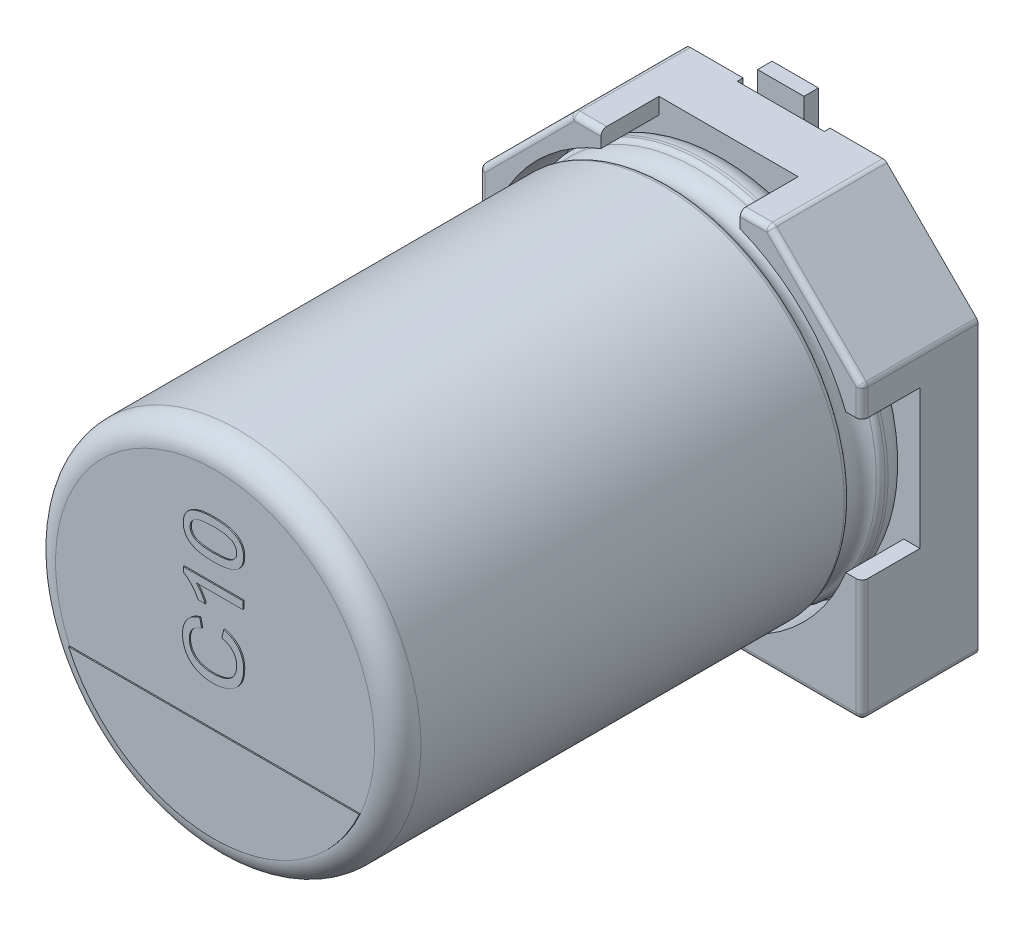
from build123d import *

# Parameters (mm, degrees)
BOSS_EXTRUDE1_DEPTH = 1
BOSS_EXTRUDE2_DEPTH = 1
SKETCH7_R           = 0.35
SPACER_PAD_DEPTH    = 0.15
SKETCH9_W           = 1.5
SKETCH9_H           = 2.35
CUT_EXTRUDE1_DEPTH  = 0.1
FILLET1_R           = 0.1
FILLET2_R           = 0.1
BOSS_EXTRUDE4_DEPTH = 0.02
TEXT_2_DEPTH        = 0.02
SKETCH19_W          = 0.8
SKETCH19_H          = 2.6
BOSS_EXTRUDE6_DEPTH = 0.25


with BuildPart() as part:
    # Sketch2 → Boss-Extrude1 (new body)
    with BuildSketch(Plane.XY):
        Polygon((-3.3, 1.7), (-1.7, 3.3), (1.7, 3.3), (3.3, 1.7), (3.3, -3.3), (-3.3, -3.3), align=None)
    extrude(amount=BOSS_EXTRUDE1_DEPTH)

    # Sketch4 → Boss-Extrude2 (add)
    with BuildSketch(Plane.XY.offset(1)):
        with BuildLine():
            Line((-3.3, 1.7), (-1.7, 3.3))
            Line((-1.7, 3.3), (-1.2, 3.3))
            Line((-1.2, 3.3), (-1.2, 3.020347662))
            ThreePointArc((-1.2, 3.020347662), (-2.298097039, 2.298097039), (-3.020347662, 1.2))
            Line((-3.020347662, 1.2), (-3.3, 1.2))
            Line((-3.3, 1.2), (-3.3, 1.7))
        make_face()
        with BuildLine():
            Line((1.7, 3.3), (3.3, 1.7))
            Line((3.3, 1.7), (3.3, 1.2))
            Line((3.3, 1.2), (3.020347662, 1.2))
            ThreePointArc((3.020347662, 1.2), (2.298097039, 2.298097039), (1.2, 3.020347662))
            Line((1.2, 3.020347662), (1.2, 3.3))
            Line((1.2, 3.3), (1.7, 3.3))
        make_face()
        with BuildLine():
            Line((3.3, -1.2), (3.3, -3.3))
            Line((3.3, -3.3), (1.2, -3.3))
            Line((1.2, -3.3), (1.2, -3.020347662))
            ThreePointArc((1.2, -3.020347662), (2.298097039, -2.298097039), (3.020347662, -1.2))
            Line((3.020347662, -1.2), (3.3, -1.2))
        make_face()
        with BuildLine():
            Line((-3.3, -1.2), (-3.3, -3.3))
            Line((-3.3, -3.3), (-1.2, -3.3))
            Line((-1.2, -3.3), (-1.2, -3.020347662))
            ThreePointArc((-1.2, -3.020347662), (-2.298097039, -2.298097039), (-3.020347662, -1.2))
            Line((-3.020347662, -1.2), (-3.3, -1.2))
        make_face()
    extrude(amount=BOSS_EXTRUDE2_DEPTH)

    # Sketch7 → Spacer Pad (add)
    with BuildSketch(Plane(origin=(0, 0, 0), x_dir=(1, 0, 0), z_dir=(0, 0, -1))):
        with Locations((-2.232271432, 1.911844843)):
            Circle(SKETCH7_R)
        with Locations((2.232271432, 1.911844843)):
            Circle(SKETCH7_R)
        with Locations((-2.232271432, -1.911844843)):
            Circle(SKETCH7_R)
        with Locations((2.232271432, -1.911844843)):
            Circle(SKETCH7_R)
    extrude(amount=SPACER_PAD_DEPTH)

    # Sketch9 → Cut-Extrude1 (cut)
    with BuildSketch(Plane(origin=(0, 0, 0), x_dir=(1, 0, 0), z_dir=(0, 0, -1))):
        with Locations((0, 2.125)):
            Rectangle(SKETCH9_W, SKETCH9_H)
        with Locations((0, -2.125)):
            Rectangle(SKETCH9_W, SKETCH9_H)
    extrude(amount=-CUT_EXTRUDE1_DEPTH, mode=Mode.SUBTRACT)

    # Fillet1
    fillet1_edges = [part.edges().sort_by_distance(p)[0] for p in [
        (3.3, -3.3, 1),
        (-3.3, -3.3, 1),
        (-3.3, 1.7, 1),
        (-1.7, 3.3, 1),
        (1.7, 3.3, 1),
        (3.3, 1.7, 1),
    ]]
    fillet(fillet1_edges, radius=FILLET1_R)

    # Sketch10 → Revolve1 (revolve)
    with BuildSketch(Plane(origin=(0, 0, 0), x_dir=(0, 0, -1), z_dir=(1, 0, 0))):
        with BuildLine():
            Line((-9.853626625, 0), (-1, 0))
            Line((-1, 0), (-1, 2.75))
            ThreePointArc((-1, 2.75), (-1.117157288, 3.032842712), (-1.4, 3.15))
            Line((-1.4, 3.15), (-1.449422929, 3.15))
            ThreePointArc((-1.449422929, 3.15), (-1.504479696, 3.133479053), (-1.541344666, 3.089375046))
            ThreePointArc((-1.541344666, 3.089375046), (-1.801990181, 2.917472047), (-2.062635697, 3.089375046))
            ThreePointArc((-2.062635697, 3.089375046), (-2.099500666, 3.133479053), (-2.154557434, 3.15))
            Line((-2.154557434, 3.15), (-9.453626625, 3.15))
            ThreePointArc((-9.453626625, 3.15), (-9.736469337, 3.032842712), (-9.853626625, 2.75))
            Line((-9.853626625, 2.75), (-9.853626625, 0))
        make_face()
    revolve(axis=Axis((0, 0, -18.9630778), (0, 0, 1)))

    # Fillet2
    fillet2_edges = [part.edges().sort_by_distance(p)[0] for p in [
        (2.2, -3.3, 2),
        (3.270710678, -3.270710678, 2),
        (3.3, 1.429289322, 2),
        (3.292387953, 1.696846987, 2),
        (1.429289322, 3.3, 2),
        (1.696846987, 3.292387953, 2),
        (-1.429289322, 3.3, 2),
        (-1.696846987, 3.292387953, 2),
        (-2.5, 2.5, 2),
        (-3.292387953, 1.696846987, 2),
        (-3.3, -2.2, 2),
        (-3.270710678, -3.270710678, 2),
        (3.3, -2.2, 2),
        (2.5, 2.5, 2),
        (-3.3, 1.429289322, 2),
        (-2.2, -3.3, 2),
    ]]
    fillet(fillet2_edges, radius=FILLET2_R)

    # Sketch13 → Boss-Extrude4 (add)
    with BuildSketch(Plane.XY.offset(9.853626625)):
        with BuildLine():
            Line((-2.506238836, -1.131930607), (2.506238836, -1.131930607))
            ThreePointArc((2.506238836, -1.131930607), (0, -2.75), (-2.506238836, -1.131930607))
        make_face()
    extrude(amount=BOSS_EXTRUDE4_DEPTH)

    # Sketch15 → Text 2 (add)
    with BuildSketch(Plane.XY.offset(9.853626625)):
        with BuildLine():
            Line((0.137389622, 0.316593633), (0.171139963, 0.461473149))
            add(Edge.make_bspline(
                [(0.171139963, 0.461473149), (0.184719205, 0.457843617), (0.211281888, 0.450743802), (0.249294555, 0.436704736), (0.284973396, 0.420954535), (0.318198658, 0.403080099), (0.348825876, 0.383025378), (0.37700883, 0.360877976), (0.402792333, 0.336641169), (0.425858287, 0.31012897), (0.446489175, 0.282031663), (0.464171898, 0.252152583), (0.479591278, 0.221021834), (0.491950748, 0.188130242), (0.501325327, 0.153719305), (0.508136304, 0.117874786), (0.512336792, 0.080509598), (0.512889354, 0.055039538), (0.513170865, 0.042063415)],
                knots=[0, 0, 0, 0, 1.145367768, 2.240481511, 3.299486216, 4.322926322, 5.312543435, 6.280301985, 7.2416403, 8.192823262, 9.141388579, 10.079393599, 11.019812878, 11.970222822, 12.938950422, 13.923894909, 14.942295558, 16, 16, 16, 16], degree=3))
            add(Edge.make_bspline(
                [(0.513170865, 0.042063415), (0.512974968, 0.028750287), (0.512591712, 0.002704216), (0.509548347, -0.035461334), (0.50408886, -0.071710574), (0.497105361, -0.106172698), (0.487517876, -0.138603304), (0.476080502, -0.169237106), (0.462232577, -0.197809744), (0.446522059, -0.224623591), (0.428664346, -0.249552903), (0.409152567, -0.273167676), (0.387446592, -0.294893809), (0.364059715, -0.315274756), (0.338683214, -0.333866555), (0.311661899, -0.351353217), (0.282519639, -0.366881226), (0.251796737, -0.381026037), (0.219790643, -0.393441241), (0.187133568, -0.404424353), (0.153760439, -0.413403647), (0.119952084, -0.421134241), (0.085424029, -0.426750142), (0.050435341, -0.431208994), (0.014771509, -0.433660561), (-0.009201459, -0.433983161), (-0.021278143, -0.434145675)],
                knots=[0, 0, 0, 0, 1.180680974, 2.309907975, 3.39230657, 4.430402719, 5.425739985, 6.38846843, 7.327253855, 8.238163682, 9.141319901, 10.044148192, 10.951882972, 11.861898394, 12.79276478, 13.739539846, 14.714057202, 15.718574761, 16.737652364, 17.7573291, 18.772768038, 19.801551793, 20.831755737, 21.873891013, 22.928945814, 24, 24, 24, 24], degree=3))
            add(Edge.make_bspline(
                [(-0.021278143, -0.434145675), (-0.034315397, -0.4339132), (-0.060073717, -0.433453889), (-0.098081116, -0.430862244), (-0.134761949, -0.426098769), (-0.17014477, -0.419495443), (-0.204305873, -0.411082573), (-0.23725329, -0.400840529), (-0.268852986, -0.388622281), (-0.299113504, -0.374745627), (-0.327665253, -0.358785546), (-0.354762577, -0.3416054), (-0.379878011, -0.322520006), (-0.403474105, -0.302187934), (-0.425149261, -0.280085417), (-0.444954877, -0.256284136), (-0.463070995, -0.230988325), (-0.479329594, -0.204201975), (-0.493595656, -0.176275134), (-0.506302564, -0.147622628), (-0.516717602, -0.118130488), (-0.525377287, -0.088032537), (-0.532271201, -0.057263976), (-0.536881183, -0.025752912), (-0.539885404, 0.006471539), (-0.540292549, 0.02819978), (-0.540498339, 0.039182288)],
                knots=[0, 0, 0, 0, 1.185610122, 2.34246615, 3.46204209, 4.547238403, 5.613845268, 6.659506797, 7.682407252, 8.692734231, 9.683951048, 10.654680354, 11.607833779, 12.549673105, 13.484816388, 14.419272854, 15.362680812, 16.31159957, 17.265732262, 18.21261905, 19.159670199, 20.10733745, 21.059306249, 22.024427552, 23.00144979, 24, 24, 24, 24], degree=3))
            add(Edge.make_bspline(
                [(-0.540498339, 0.039182288), (-0.54027585, 0.051472155), (-0.539838527, 0.075629106), (-0.53596558, 0.111030265), (-0.53016218, 0.145076857), (-0.521400985, 0.17750367), (-0.510653256, 0.208616176), (-0.496791219, 0.237924274), (-0.481084534, 0.266024209), (-0.462639265, 0.292395393), (-0.442059798, 0.317116672), (-0.419396701, 0.339965227), (-0.394799964, 0.360899322), (-0.368077184, 0.379659831), (-0.339408707, 0.396504218), (-0.308850674, 0.411613497), (-0.276208278, 0.424627676), (-0.253468798, 0.431587541), (-0.241890133, 0.435131419)],
                knots=[0, 0, 0, 0, 1.098215313, 2.158650937, 3.179873416, 4.182349117, 5.157851008, 6.118027029, 7.076341197, 8.032298369, 8.990121974, 9.948357669, 10.905435138, 11.873450097, 12.863034414, 13.874936208, 14.917943528, 16, 16, 16, 16], degree=3))
            Line((-0.241890133, 0.435131419), (-0.210815123, 0.290251903))
            add(Edge.make_bspline(
                [(-0.210815123, 0.290251903), (-0.21970095, 0.287406696), (-0.237093262, 0.281837744), (-0.261880399, 0.271949526), (-0.284890959, 0.26127058), (-0.305968529, 0.249546525), (-0.325118157, 0.236751953), (-0.342572578, 0.223181488), (-0.358006003, 0.208509995), (-0.371774287, 0.193035906), (-0.383503548, 0.176359634), (-0.393897604, 0.158872143), (-0.402497099, 0.140204709), (-0.409770496, 0.120625878), (-0.415306335, 0.099952647), (-0.419201016, 0.078269202), (-0.421455067, 0.05555649), (-0.421789822, 0.040079052), (-0.421960554, 0.032185266)],
                knots=[0, 0, 0, 0, 1.235697765, 2.418642872, 3.532555292, 4.594392283, 5.610119701, 6.580908344, 7.519430642, 8.427315627, 9.319973334, 10.216139639, 11.118687699, 12.038725643, 12.980015607, 13.949697744, 14.954307006, 16, 16, 16, 16], degree=3))
            add(Edge.make_bspline(
                [(-0.421960554, 0.032185266), (-0.42182894, 0.023122531), (-0.421570094, 0.005298806), (-0.418741414, -0.020887312), (-0.414566199, -0.046031584), (-0.408336958, -0.06996279), (-0.400471327, -0.092727501), (-0.391074044, -0.1144289), (-0.379637086, -0.134923416), (-0.366527285, -0.154190234), (-0.351810113, -0.172119905), (-0.335998775, -0.188775555), (-0.319056253, -0.204115277), (-0.300881808, -0.217955028), (-0.281409051, -0.230297385), (-0.260823414, -0.241466755), (-0.238987177, -0.251110914), (-0.208358467, -0.262011565), (-0.168833348, -0.2727293), (-0.120495718, -0.282252213), (-0.071437696, -0.288256875), (-0.038444502, -0.28892902), (-0.021895528, -0.289266159)],
                knots=[0, 0, 0, 0, 0.935100075, 1.839065892, 2.715632844, 3.564034634, 4.388093667, 5.199800233, 6.00171917, 6.806945003, 7.602082793, 8.393428172, 9.17553264, 9.958694158, 10.748327009, 11.553054559, 12.374096334, 13.209545573, 14.906836637, 16.595465087, 18.292327764, 20, 20, 20, 20], degree=3))
            add(Edge.make_bspline(
                [(-0.021895528, -0.289266159), (-0.001088295, -0.28888169), (0.039347759, -0.288134525), (0.097860474, -0.280941105), (0.152411861, -0.269796756), (0.194923463, -0.256480088), (0.226325575, -0.243084208), (0.248317261, -0.232252213), (0.268667217, -0.219887416), (0.287491124, -0.206297945), (0.304734045, -0.191308606), (0.320487583, -0.175128268), (0.334903322, -0.157753307), (0.347306436, -0.138977849), (0.35831932, -0.119524584), (0.368112186, -0.099638997), (0.376394559, -0.079308568), (0.382828475, -0.058451271), (0.388388272, -0.03736), (0.392020193, -0.015802455), (0.394069935, 0.006215216), (0.39444386, 0.020999538), (0.39463308, 0.02848096)],
                knots=[0, 0, 0, 0, 2.106854985, 4.094388766, 5.961441423, 7.741458329, 8.594569961, 9.418076185, 10.222480919, 11.003619353, 11.767127393, 12.533696482, 13.289066307, 14.050325982, 14.809648647, 15.552384038, 16.294338903, 17.030544626, 17.761979889, 18.502240791, 19.242077596, 20, 20, 20, 20], degree=3))
            add(Edge.make_bspline(
                [(0.39463308, 0.02848096), (0.39444584, 0.037409013), (0.394075974, 0.055045074), (0.390838523, 0.080901779), (0.386067714, 0.105827286), (0.378705874, 0.129519626), (0.369692165, 0.152297488), (0.358576684, 0.173974247), (0.345208005, 0.194481731), (0.330029126, 0.214061155), (0.312758155, 0.232351457), (0.293534236, 0.249113535), (0.27226973, 0.264151013), (0.249305901, 0.278094539), (0.223956735, 0.289809664), (0.196977778, 0.300660635), (0.167925608, 0.309702449), (0.147714502, 0.314263574), (0.137389622, 0.316593633)],
                knots=[0, 0, 0, 0, 1.013374089, 2.001772144, 2.95501459, 3.891367103, 4.814208647, 5.733921849, 6.652182523, 7.590185968, 8.54346024, 9.504121027, 10.481158517, 11.497760682, 12.549996529, 13.647863555, 14.798406869, 16, 16, 16, 16], degree=3))
        make_face()
        with BuildLine():
            Line((0.5, 1.054162076), (0.5, 0.922453425))
            Line((0.5, 0.922453425), (-0.300541641, 0.922453425))
            add(Edge.make_bspline(
                [(-0.300541641, 0.922453425), (-0.293231008, 0.914867413), (-0.278036657, 0.899100718), (-0.256498368, 0.872525657), (-0.234933587, 0.842661098), (-0.213972558, 0.810225794), (-0.193975357, 0.777264423), (-0.17626551, 0.745237618), (-0.16122985, 0.714930294), (-0.153017422, 0.694960397), (-0.149076693, 0.685377855)],
                knots=[0, 0, 0, 0, 0.893410138, 1.856855062, 2.898678959, 4.017251132, 5.132047586, 6.168690112, 7.121247105, 8, 8, 8, 8], degree=3))
            Line((-0.149076693, 0.685377855), (-0.270495605, 0.685377855))
            add(Edge.make_bspline(
                [(-0.270495605, 0.685377855), (-0.278975965, 0.701832813), (-0.295690253, 0.734264562), (-0.324502419, 0.780173657), (-0.356038954, 0.822817654), (-0.389687464, 0.861943114), (-0.424153619, 0.896834541), (-0.458713989, 0.92646811), (-0.492500166, 0.951068711), (-0.516061848, 0.963453197), (-0.527327474, 0.969374632)],
                knots=[0, 0, 0, 0, 1.141359047, 2.249551097, 3.338622382, 4.409719606, 5.42990334, 6.36011437, 7.215916014, 8, 8, 8, 8], degree=3))
            Line((-0.527327474, 0.969374632), (-0.527327474, 1.054162076))
            Line((-0.527327474, 1.054162076), (0.5, 1.054162076))
        make_face()
        with BuildLine():
            add(Edge.make_bspline(
                [(-0.006666715, 1.383433702), (-0.021348161, 1.383566435), (-0.05010293, 1.383826401), (-0.092176441, 1.385437954), (-0.132131476, 1.388254232), (-0.169935305, 1.392449442), (-0.205733207, 1.397454989), (-0.239429592, 1.403867562), (-0.271062963, 1.411184505), (-0.300511033, 1.419860467), (-0.328087047, 1.429543425), (-0.353841772, 1.440380117), (-0.37776862, 1.452612868), (-0.400036721, 1.465712401), (-0.420488167, 1.479932501), (-0.439160067, 1.495255191), (-0.456112672, 1.511706922), (-0.471148561, 1.529458766), (-0.484427043, 1.548340503), (-0.495950274, 1.568301249), (-0.505765593, 1.58948262), (-0.513455163, 1.611944973), (-0.519644259, 1.635469504), (-0.524219468, 1.660149349), (-0.526911348, 1.686028494), (-0.527187198, 1.703712594), (-0.527327474, 1.712705329)],
                knots=[0, 0, 0, 0, 1.514579231, 2.966422906, 4.342888004, 5.645649548, 6.889653673, 8.070797339, 9.183112822, 10.237837631, 11.23608981, 12.196917133, 13.117904763, 14.006315217, 14.860292005, 15.684850496, 16.495566347, 17.293863258, 18.081168691, 18.873799386, 19.668575398, 20.485475899, 21.319695627, 22.176102692, 23.072510053, 24, 24, 24, 24], degree=3))
            add(Edge.make_bspline(
                [(-0.527327474, 1.712705329), (-0.526946, 1.725900851), (-0.52619658, 1.751823984), (-0.519894074, 1.789619905), (-0.509601404, 1.825365362), (-0.495164597, 1.858771713), (-0.477005039, 1.889551399), (-0.454609486, 1.916814349), (-0.428796734, 1.940721356), (-0.398935516, 1.960698215), (-0.365916888, 1.978175601), (-0.32956484, 1.993697591), (-0.289928116, 2.007730365), (-0.254447235, 2.017688005), (-0.223818989, 2.024790857), (-0.198557662, 2.029492369), (-0.171300552, 2.033395569), (-0.142113597, 2.036385948), (-0.111029533, 2.038839483), (-0.078029007, 2.040734235), (-0.043029539, 2.041696016), (-0.019014885, 2.041881553), (-0.006666715, 2.041976955)],
                knots=[0, 0, 0, 0, 1.134369906, 2.228515181, 3.285355733, 4.326599491, 5.350616376, 6.348601676, 7.350764122, 8.365406289, 9.429174435, 10.560286681, 11.762070813, 13.043401781, 13.727542782, 14.465843617, 15.252693982, 16.095180924, 16.988916914, 17.934437918, 18.937902156, 20, 20, 20, 20], degree=3))
            add(Edge.make_bspline(
                [(-0.006666715, 2.041976955), (0.007945774, 2.041841762), (0.036494148, 2.041577635), (0.078230238, 2.04000893), (0.117884052, 2.037024283), (0.155547122, 2.033354152), (0.191116489, 2.027792706), (0.224685881, 2.021840905), (0.256141409, 2.014381948), (0.285591451, 2.005734402), (0.313215971, 1.996076626), (0.339056183, 1.985437014), (0.363042027, 1.973440215), (0.385265653, 1.96031548), (0.405728202, 1.94602942), (0.424578214, 1.930841433), (0.441550249, 1.914321801), (0.456560003, 1.896506184), (0.470080131, 1.877750835), (0.481656405, 1.857683963), (0.49124711, 1.836393055), (0.499446696, 1.814020456), (0.50545487, 1.790339138), (0.510054034, 1.765535857), (0.512762354, 1.739519222), (0.513032816, 1.72176661), (0.513170865, 1.712705329)],
                knots=[0, 0, 0, 0, 1.509004079, 2.9481365, 4.311841541, 5.615149582, 6.854413858, 8.028470806, 9.134999426, 10.19077436, 11.196702255, 12.155743144, 13.07445799, 13.963752978, 14.818580019, 15.649443378, 16.460966408, 17.260058134, 18.052243746, 18.845663614, 19.647670084, 20.461076897, 21.302979722, 22.167206202, 23.06450606, 24, 24, 24, 24], degree=3))
            add(Edge.make_bspline(
                [(0.513170865, 1.712705329), (0.512831976, 1.700824938), (0.512171236, 1.677661445), (0.507681916, 1.643832872), (0.499780502, 1.612082952), (0.489183591, 1.582143893), (0.475009612, 1.554352217), (0.457764199, 1.528575231), (0.437848585, 1.504294964), (0.422135623, 1.490317766), (0.414183582, 1.483244164)],
                knots=[0, 0, 0, 0, 1.10322584, 2.150986741, 3.161425019, 4.136713905, 5.093944212, 6.049774532, 7.013026876, 8, 8, 8, 8], degree=3))
            add(Edge.make_bspline(
                [(0.414183582, 1.483244164), (0.402438803, 1.475102286), (0.378220566, 1.458313384), (0.336926225, 1.43866343), (0.291466953, 1.421135323), (0.240950845, 1.407378973), (0.185779952, 1.396604321), (0.125846017, 1.388822333), (0.061174934, 1.384418493), (0.016457663, 1.383769376), (-0.006666715, 1.383433702)],
                knots=[0, 0, 0, 0, 0.779365345, 1.607084704, 2.489375761, 3.438383567, 4.461919411, 5.557722155, 6.737039282, 8, 8, 8, 8], degree=3))
        make_face()
        with BuildLine():
            add(Edge.make_bspline(
                [(-0.007078304, 1.515142353), (0.012680939, 1.515273129), (0.050504503, 1.515523464), (0.104541989, 1.518138853), (0.153291178, 1.522641137), (0.196684572, 1.528593451), (0.234780871, 1.536452916), (0.267482993, 1.546321403), (0.295183438, 1.557445536), (0.31753888, 1.571211439), (0.335761826, 1.586283582), (0.351434149, 1.601844541), (0.364755265, 1.618260409), (0.375862359, 1.635424076), (0.384271921, 1.653601848), (0.39036719, 1.672594954), (0.393874924, 1.692407528), (0.394378919, 1.705900791), (0.39463308, 1.712705329)],
                knots=[0, 0, 0, 0, 1.89448813, 3.626469325, 5.185477471, 6.587276848, 7.82441448, 8.910550357, 9.859733512, 10.6775885, 11.416198291, 12.123144072, 12.791880183, 13.439617036, 14.078171869, 14.70637855, 15.347637704, 16, 16, 16, 16], degree=3))
            add(Edge.make_bspline(
                [(0.39463308, 1.712705329), (0.394373432, 1.719508217), (0.393858557, 1.732998211), (0.390427197, 1.752855758), (0.384021797, 1.771777976), (0.375628132, 1.789917263), (0.364803962, 1.807286144), (0.351188379, 1.823477079), (0.335563636, 1.839212453), (0.31713255, 1.854123894), (0.294785049, 1.867980664), (0.267067011, 1.879083781), (0.234370941, 1.888961166), (0.196338005, 1.896794927), (0.153019756, 1.902789575), (0.104403712, 1.907259025), (0.050436387, 1.909893637), (0.012681078, 1.910139586), (-0.007078304, 1.910268304)],
                knots=[0, 0, 0, 0, 0.652578524, 1.294050225, 1.924494109, 2.563260593, 3.207694917, 3.880813851, 4.587993952, 5.331957758, 6.150083828, 7.099581593, 8.186077474, 9.42362516, 10.819375359, 12.378900244, 14.104883934, 16, 16, 16, 16], degree=3))
            add(Edge.make_bspline(
                [(-0.007078304, 1.910268304), (-0.02642651, 1.910143578), (-0.063496939, 1.909904609), (-0.116493392, 1.907203811), (-0.164424345, 1.902971418), (-0.207333987, 1.897182177), (-0.245175733, 1.889488277), (-0.278030144, 1.880156626), (-0.305827152, 1.869036569), (-0.328845978, 1.85581486), (-0.34772766, 1.841096453), (-0.364071399, 1.825721681), (-0.377971216, 1.809306174), (-0.389121855, 1.791559098), (-0.398117775, 1.773052475), (-0.404308997, 1.75336107), (-0.40811269, 1.732678434), (-0.408561444, 1.718484209), (-0.408789689, 1.711264765)],
                knots=[0, 0, 0, 0, 1.850066095, 3.544656626, 5.0727657, 6.45041401, 7.682899467, 8.762389858, 9.712573485, 10.538438529, 11.291566246, 11.996865408, 12.681389046, 13.341983376, 13.996294293, 14.643563182, 15.31009126, 16, 16, 16, 16], degree=3))
            add(Edge.make_bspline(
                [(-0.408789689, 1.711264765), (-0.408612967, 1.704459779), (-0.408264494, 1.691041217), (-0.404876647, 1.671409791), (-0.399346117, 1.652720616), (-0.39136817, 1.635098068), (-0.381470743, 1.618367712), (-0.369432495, 1.602509246), (-0.354882974, 1.587902895), (-0.343982304, 1.579112371), (-0.338407878, 1.57461704)],
                knots=[0, 0, 0, 0, 1.021462953, 2.014194051, 2.982449609, 3.941891643, 4.91211921, 5.897280499, 6.924703483, 8, 8, 8, 8], degree=3))
            add(Edge.make_bspline(
                [(-0.338407878, 1.57461704), (-0.330223621, 1.569721616), (-0.312940192, 1.559383511), (-0.282899948, 1.547820081), (-0.248509791, 1.537565623), (-0.209345493, 1.529236978), (-0.165460838, 1.523074155), (-0.116925816, 1.518301083), (-0.063560809, 1.515797668), (-0.026425263, 1.515366818), (-0.007078304, 1.515142353)],
                knots=[0, 0, 0, 0, 0.671109831, 1.417242661, 2.260125669, 3.199948126, 4.23589883, 5.382398214, 6.636276086, 8, 8, 8, 8], degree=3))
        make_face(mode=Mode.SUBTRACT)
    extrude(amount=TEXT_2_DEPTH)

    # Sketch19 → Boss-Extrude6 (add)
    with BuildSketch(Plane(origin=(0, 0, 0.1), x_dir=(1, 0, 0), z_dir=(0, 0, -1))):
        with Locations((0, 2.35)):
            Rectangle(SKETCH19_W, SKETCH19_H)
        with Locations((0, -2.35)):
            Rectangle(SKETCH19_W, SKETCH19_H)
    extrude(amount=BOSS_EXTRUDE6_DEPTH)


solid = part.part
